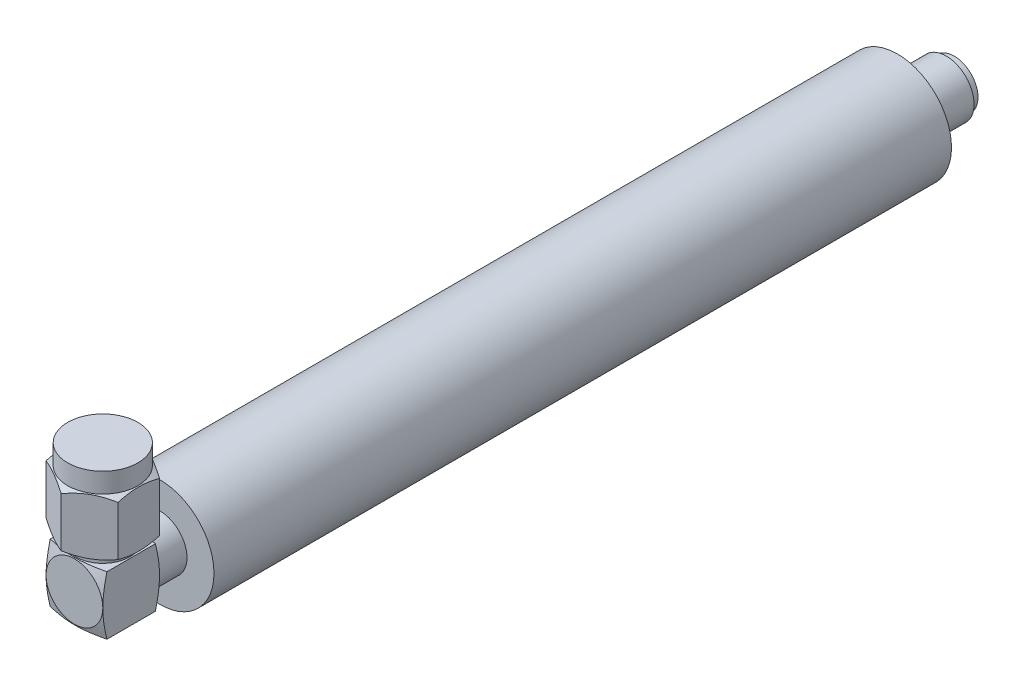
from build123d import *

# Parameters (mm, degrees)
SKETCH1_R           = 6
BOSS_EXTRUDE1_DEPTH = 81.92
SKETCH3_R           = 3
BOSS_EXTRUDE2_DEPTH = 3.2
SKETCH4_W           = 6.3
SKETCH4_H           = 6.3
BOSS_EXTRUDE3_DEPTH = 3.25
SKETCH10_R          = 3
BOSS_EXTRUDE6_DEPTH = 1
BOSS_EXTRUDE7_DEPTH = 8.5
SKETCH12_R          = 5.645731703
SKETCH12_R_2        = 3.9
CUT_EXTRUDE2_DEPTH  = 2.2
SKETCH14_R          = 3.959834879
SKETCH14_R_2        = 2.65
CUT_EXTRUDE3_DEPTH  = 0.89


with BuildPart() as part:
    # Sketch1 → Boss-Extrude1 (new body)
    with BuildSketch(Plane.XY):
        Circle(SKETCH1_R)
    extrude(amount=BOSS_EXTRUDE1_DEPTH)

    # Sketch2 → Revolve1 (revolve)
    with BuildSketch(Plane(origin=(0, 0, 0), x_dir=(1, 0, 0), z_dir=(0, 1, 0))):
        Polygon((-1.987053294, 0), (-1.987053294, 1.5), (-3.1, 1.5), (-3.1, 6.3), (0, 6.3), (0, 0), align=None)
    revolve(axis=Axis((0, 0, 88.862708705), (0, 0, 1)))

    # Sketch3 → Boss-Extrude2 (add)
    with BuildSketch(Plane.XY.offset(81.92)):
        Circle(SKETCH3_R)
    extrude(amount=BOSS_EXTRUDE2_DEPTH)

    # Sketch4 → Boss-Extrude3 (add, symmetric)
    with BuildSketch(Plane(origin=(0, 0, 0), x_dir=(1, 0, 0), z_dir=(0, 1, 0))):
        with Locations((0, -88.27)):
            Rectangle(SKETCH4_W, SKETCH4_H)
    extrude(amount=BOSS_EXTRUDE3_DEPTH, both=True)

    # Sketch9 → Cut-Revolve3 (revolve, cut)
    with BuildSketch(Plane(origin=(0, 0, 0), x_dir=(1, 0, 0), z_dir=(0, 1, 0))):
        Polygon((-3.15, -91.42), (-4.65, -90.92), (-4.65, -91.42), align=None)
        Polygon((-3.15, -85.12), (-4.65, -85.12), (-4.65, -85.62), align=None)
    revolve(axis=Axis((0, 0, 97.04036036), (0, 0, -1)), mode=Mode.SUBTRACT)

    # Sketch10 → Boss-Extrude6 (add, symmetric)
    with BuildSketch(Plane(origin=(0, 3.25, 0), x_dir=(1, 0, 0), z_dir=(0, 1, 0))):
        with Locations((0, -88.27)):
            Circle(SKETCH10_R)
    extrude(amount=BOSS_EXTRUDE6_DEPTH, both=True)

    # Sketch11 → Boss-Extrude7 (add)
    with BuildSketch(Plane(origin=(0, 4.25, 0), x_dir=(1, 0, 0), z_dir=(0, 1, 0))):
        Polygon((0, -83.651197846), (-4, -85.960598923), (-4, -90.579401077), (0, -92.888802154), (4, -90.579401077), (4, -85.960598923), align=None)
    extrude(amount=BOSS_EXTRUDE7_DEPTH)

    # Sketch12 → Cut-Extrude2 (cut)
    with BuildSketch(Plane(origin=(0, 12.75, 0), x_dir=(1, 0, 0), z_dir=(0, 1, 0))):
        with Locations((0, -88.27)):
            Circle(SKETCH12_R)
        with Locations((0, -88.27)):
            Circle(SKETCH12_R_2, mode=Mode.SUBTRACT)
    extrude(amount=-CUT_EXTRUDE2_DEPTH, mode=Mode.SUBTRACT)

    # Sketch13 → Cut-Revolve4 (revolve, cut)
    with BuildSketch(Plane(origin=(0, 0, 0), x_dir=(0, 0, -1), z_dir=(1, 0, 0))):
        Polygon((-92.17, 10.55), (-92.888802154, 10.15), (-92.888802154, 10.55), align=None)
        Polygon((-92.888802154, 4.65), (-92.17, 4.25), (-92.888802154, 4.25), align=None)
    revolve(axis=Axis((0, 13.752185795, 88.27), (0, -1, 0)), mode=Mode.SUBTRACT)

    # Sketch14 → Cut-Extrude3 (cut)
    with BuildSketch(Plane(origin=(0, 0, -6.3), x_dir=(-1, 0, 0), z_dir=(0, 0, -1))):
        Circle(SKETCH14_R)
        Circle(SKETCH14_R_2, mode=Mode.SUBTRACT)
    extrude(amount=-CUT_EXTRUDE3_DEPTH, mode=Mode.SUBTRACT)


solid = part.part
